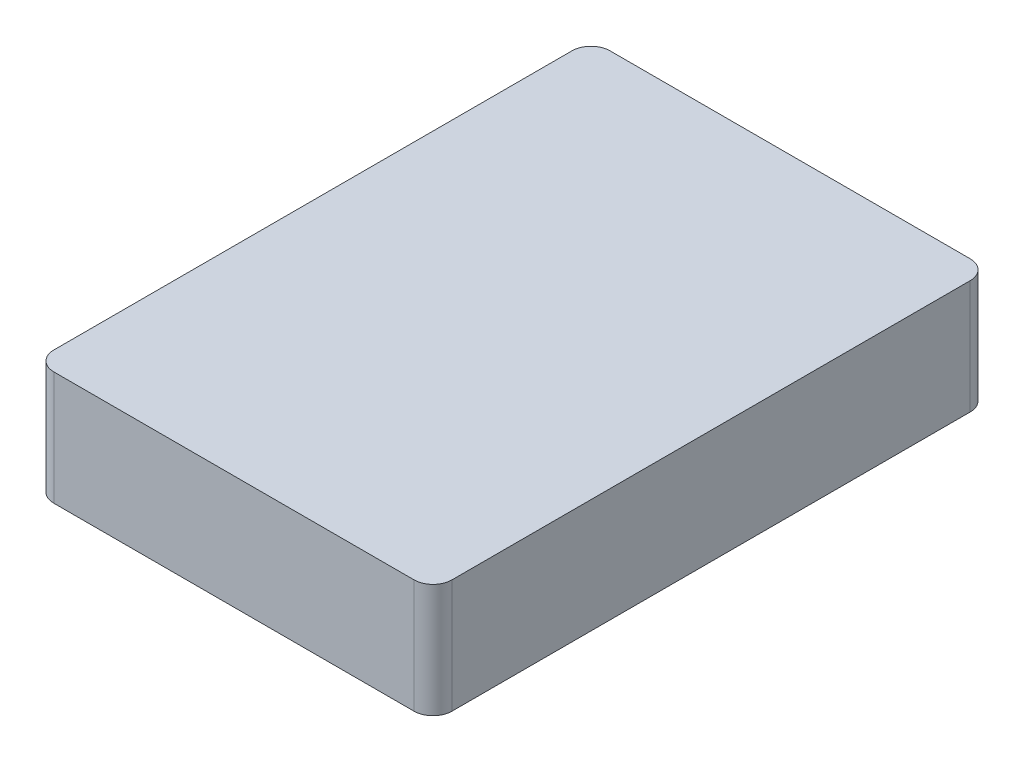
from build123d import *

# Parameters (mm, degrees)
BOSS_EXTRUDE1_DEPTH = 18


with BuildPart() as part:
    # Sketch1 → Boss-Extrude1 (new body)
    with BuildSketch(Plane(origin=(0, 0, 0), x_dir=(1, 0, 0), z_dir=(0, 1, 0))):
        with BuildLine():
            Line((28.5, -44), (-28.5, -44))
            ThreePointArc((-28.5, -44), (-30.621320344, -43.121320344), (-31.5, -41))
            Line((-31.5, -41), (-31.5, 41))
            ThreePointArc((-31.5, 41), (-30.621320344, 43.121320344), (-28.5, 44))
            Line((-28.5, 44), (28.5, 44))
            ThreePointArc((28.5, 44), (30.621320344, 43.121320344), (31.5, 41))
            Line((31.5, 41), (31.5, -41))
            ThreePointArc((31.5, -41), (30.621320344, -43.121320344), (28.5, -44))
        make_face()
    extrude(amount=BOSS_EXTRUDE1_DEPTH)


solid = part.part
